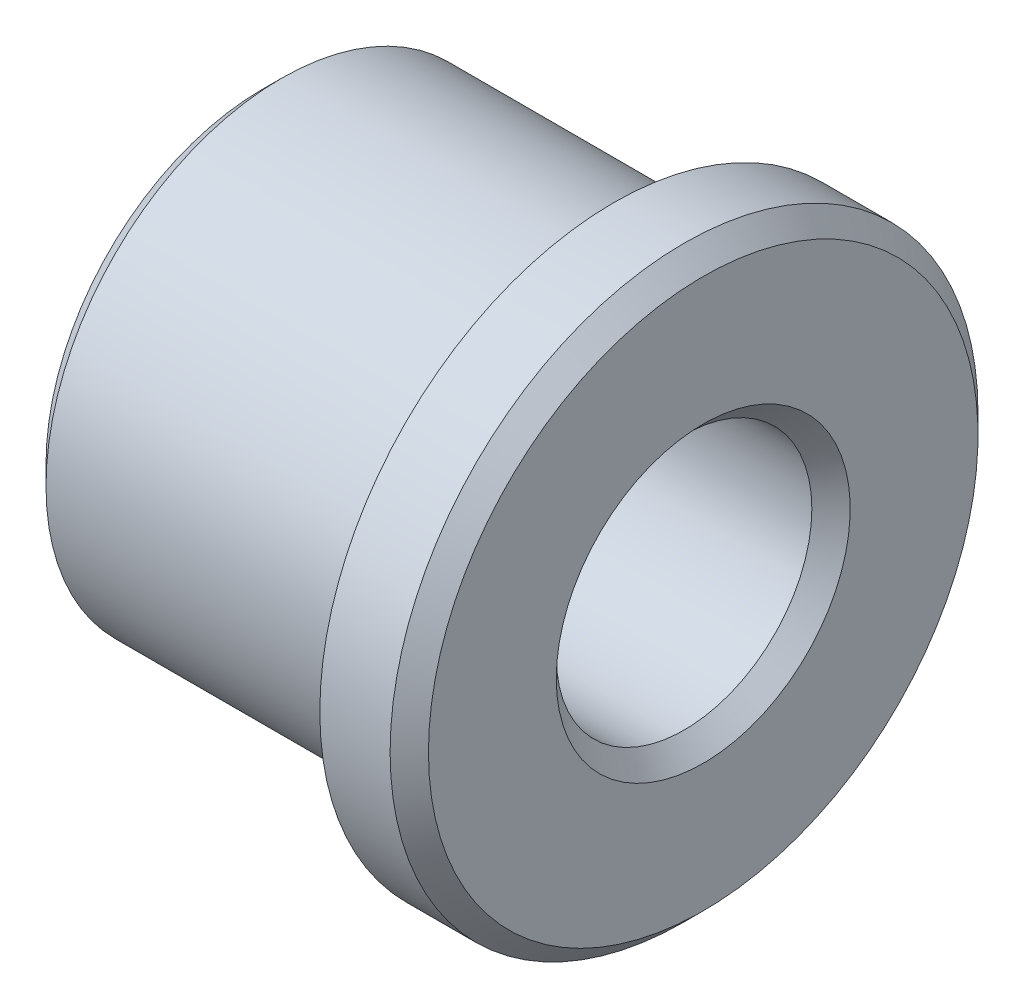
from build123d import *

# Parameters (mm, degrees)
CHANFREIN1_SIZE = 1.5


with BuildPart() as part:
    # Esquisse1 → Révolution1 (revolve)
    with BuildSketch(Plane.XY, mode=Mode.PRIVATE) as r_volution1_sk:
        Polygon((0, 10), (0, 18.425), (27.5, 18.425), (27.5, 23), (34.5, 23), (34.5, 10), align=None)
    revolve(r_volution1_sk.sketch.rotate(Axis((-4.444335788, 0, 0), (1, 0, 0)), 90), axis=Axis((-4.444335788, 0, 0), (1, 0, 0)))  # turned: the seam where the file's is

    # Chanfrein1
    chanfrein1_edges = [part.edges().sort_by_distance(p)[0] for p in [
        (0, 0, -18.425),
        (0, 0, -10),
        (34.5, 0, -10),
        (34.5, 0, -23),
    ]]
    chamfer(chanfrein1_edges, length=CHANFREIN1_SIZE)


solid = part.part
